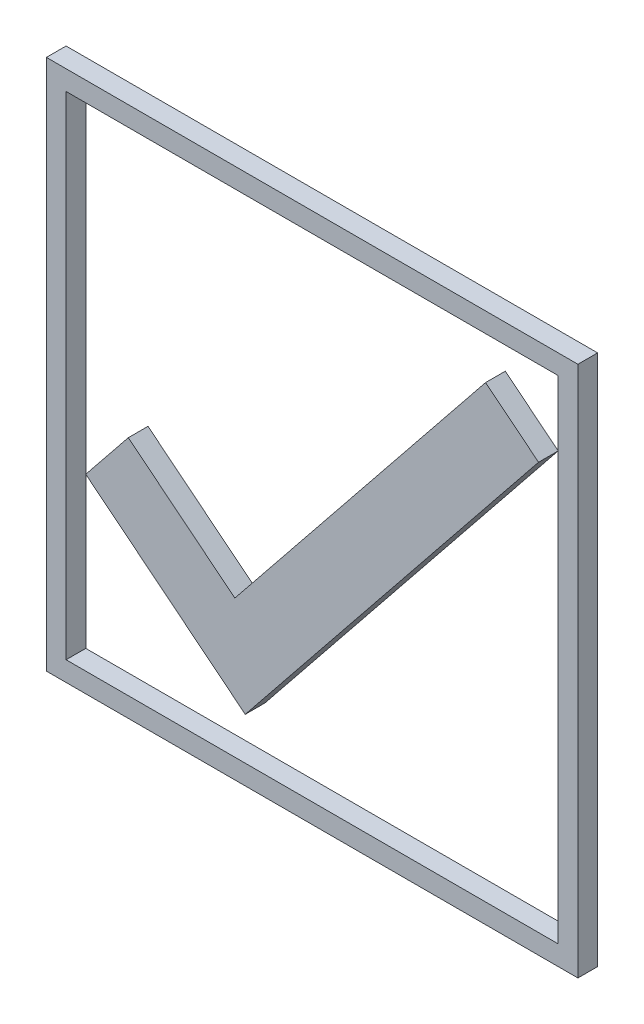
from build123d import *

# Parameters (mm, degrees)
SKETCH1_W           = 54
SKETCH1_H           = 54
SKETCH1_W_2         = 50
SKETCH1_H_2         = 50
BOSS_EXTRUDE1_DEPTH = 2


with BuildPart() as part:
    # Sketch1 → Boss-Extrude1 (new body)
    with BuildSketch(Plane.XY):
        Rectangle(SKETCH1_W, SKETCH1_H)
        Rectangle(SKETCH1_W_2, SKETCH1_H_2, mode=Mode.SUBTRACT)
        Polygon((-7.852659733, -10.999258133), (-12.17491912, -16.377740612), (-6.796436641, -20.7), (-2.474177253, -15.32151752), align=None)
        Polygon((-18.677740612, -2.3), (-23, -7.67848248), (-12.17491912, -16.377740612), (-7.852659733, -10.999258133), align=None)
        Polygon((17.62151752, 20.7), (-7.852659733, -10.999258133), (-2.474177253, -15.32151752), (23, 16.377740612), align=None)
    extrude(amount=BOSS_EXTRUDE1_DEPTH)


solid = part.part
